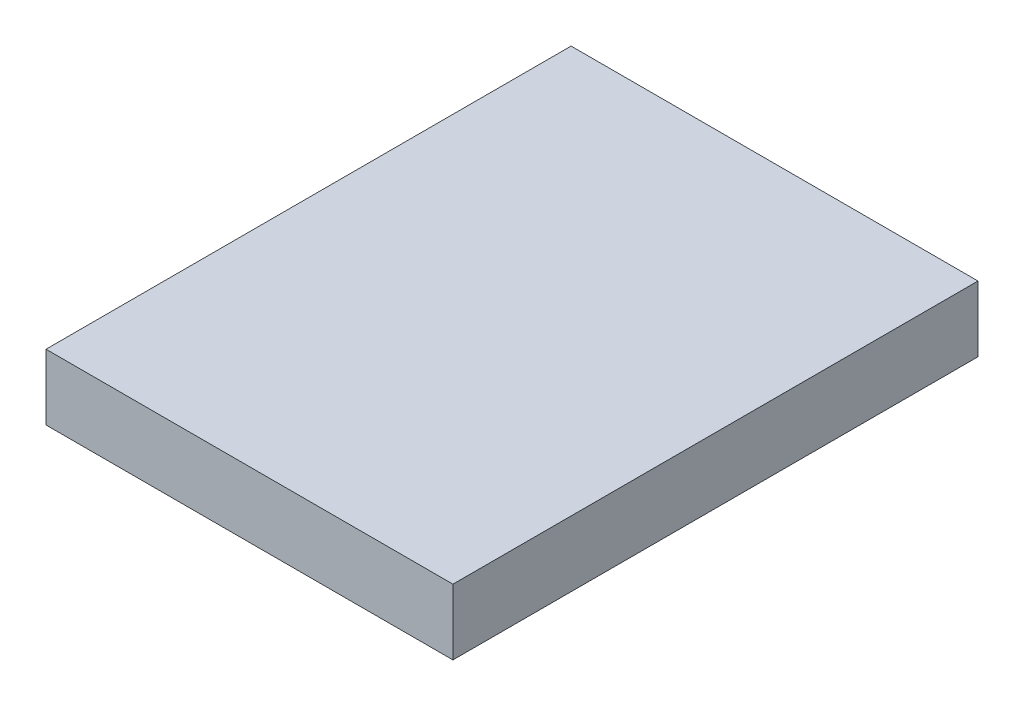
from build123d import *

# Parameters (mm, degrees)
CROQUIS1_W              = 31
CROQUIS1_H              = 40
SALIENTE_EXTRUIR1_DEPTH = 5


with BuildPart() as part:
    # Croquis1 → Saliente-Extruir1 (new body)
    with BuildSketch(Plane(origin=(0, 0, 0), x_dir=(1, 0, 0), z_dir=(0, 1, 0))):
        Rectangle(CROQUIS1_W, CROQUIS1_H)
    extrude(amount=SALIENTE_EXTRUIR1_DEPTH)


solid = part.part
